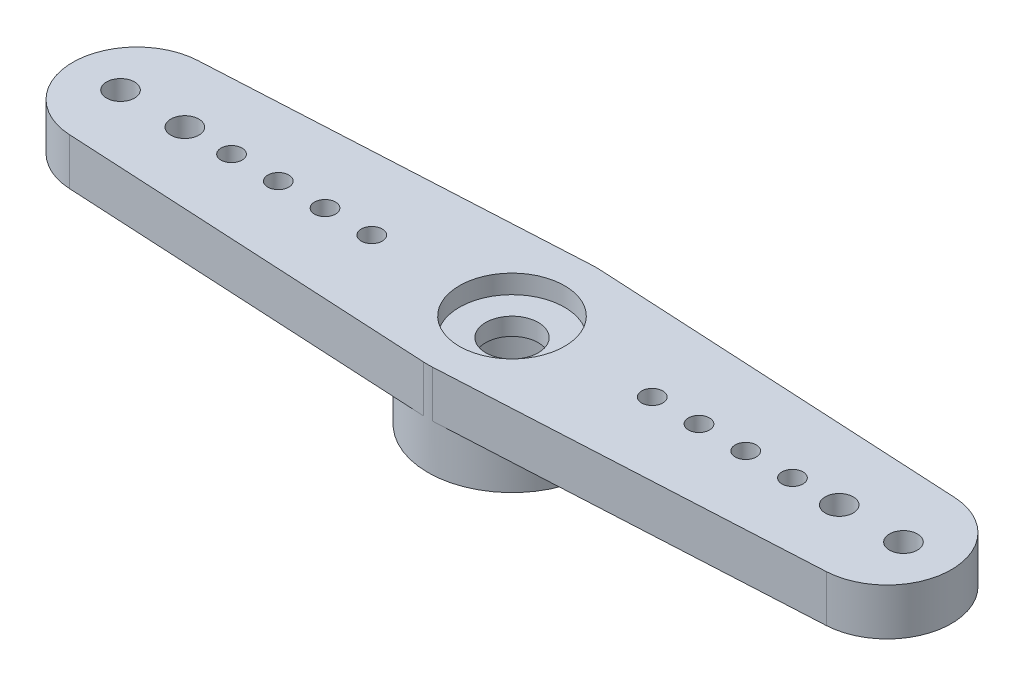
from build123d import *

# Parameters (mm, degrees)
SKETCH3_R           = 0.6
SKETCH3_R_2         = 0.45
SKETCH3_R_3         = 2.425
BOSS_EXTRUDE1_DEPTH = 2


with BuildPart() as part:
    # Sketch2 → Revolve1 (revolve)
    with BuildSketch(Plane.XY):
        Polygon((2.25, 2), (2.25, 1.2), (1.125, 1.2), (1.125, 0.45), (2.425, 0.45), (2.425, -2), (3.6, -2), (3.6, 2), align=None)
    revolve(axis=Axis((0, 55, 0), (0, -1, 0)))

    # Sketch3 → Boss-Extrude1 (add)
    with BuildSketch(Plane(origin=(0, 0, 0), x_dir=(1, 0, 0), z_dir=(0, 1, 0))):
        with BuildLine():
            Line((0.190654206, -3.594947979), (16.195638629, -2.746140818))
            ThreePointArc((16.195638629, -2.746140818), (18.8, 0), (16.195638629, 2.746140818))
            Line((16.195638629, 2.746140818), (0.190654206, 3.594947979))
            ThreePointArc((0.190654206, 3.594947979), (0, 3.6), (-0.190654206, 3.594947979))
            Line((-0.190654206, 3.594947979), (-16.195638629, 2.746140818))
            ThreePointArc((-16.195638629, 2.746140818), (-18.8, 0), (-16.195638629, -2.746140818))
            Line((-16.195638629, -2.746140818), (-0.190654206, -3.594947979))
            ThreePointArc((-0.190654206, -3.594947979), (0, -3.6), (0.190654206, -3.594947979))
        make_face()
        with Locations((-16.75, 0)):
            Circle(SKETCH3_R, mode=Mode.SUBTRACT)
        with Locations((16.75, 0)):
            Circle(SKETCH3_R, mode=Mode.SUBTRACT)
        with Locations((-14, 0)):
            Circle(SKETCH3_R, mode=Mode.SUBTRACT)
        with Locations((14, 0)):
            Circle(SKETCH3_R, mode=Mode.SUBTRACT)
        with Locations((-12, 0)):
            Circle(SKETCH3_R_2, mode=Mode.SUBTRACT)
        with Locations((-10, 0)):
            Circle(SKETCH3_R_2, mode=Mode.SUBTRACT)
        with Locations((-8, 0)):
            Circle(SKETCH3_R_2, mode=Mode.SUBTRACT)
        with Locations((-6, 0)):
            Circle(SKETCH3_R_2, mode=Mode.SUBTRACT)
        with Locations((6, 0)):
            Circle(SKETCH3_R_2, mode=Mode.SUBTRACT)
        with Locations((8, 0)):
            Circle(SKETCH3_R_2, mode=Mode.SUBTRACT)
        with Locations((10, 0)):
            Circle(SKETCH3_R_2, mode=Mode.SUBTRACT)
        with Locations((12, 0)):
            Circle(SKETCH3_R_2, mode=Mode.SUBTRACT)
        Circle(SKETCH3_R_3, mode=Mode.SUBTRACT)
    extrude(amount=BOSS_EXTRUDE1_DEPTH)


solid = part.part
